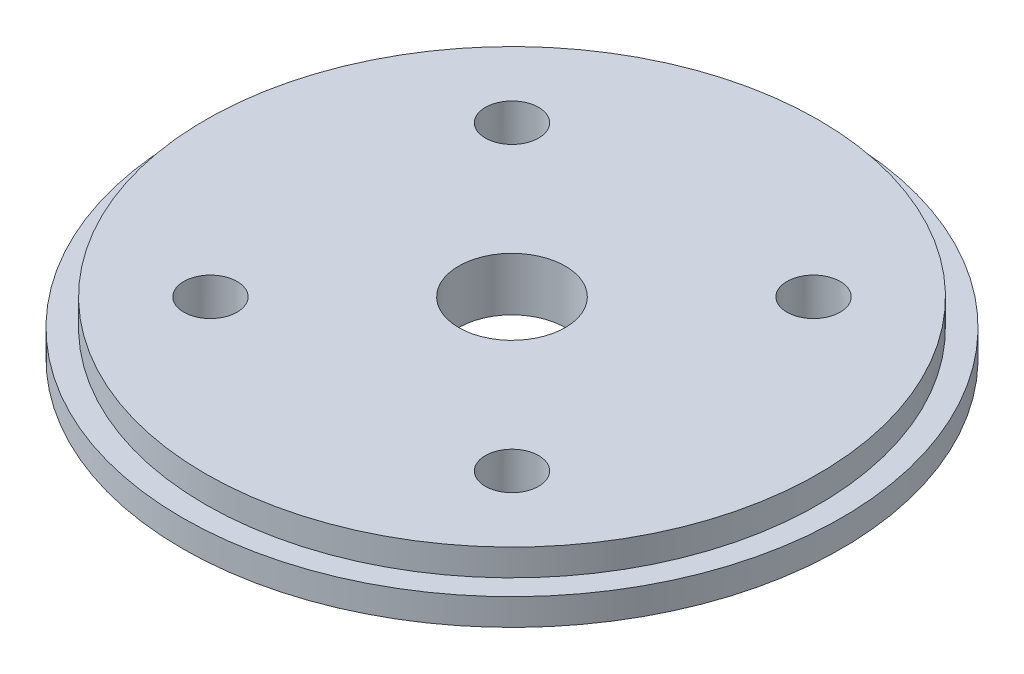
from build123d import *

# Parameters (mm, degrees)
SKETCH2_R                   = 39.2557
BOSS_EXTRUDE1_DEPTH         = 6.35
SKETCH4_R                   = 39.2557
SKETCH4_R_2                 = 36.5125
CUT_EXTRUDE1_DEPTH          = 3.175
F_1_4_0_25_DIAMETER_HOLE1_D = 6.35
F_1_2_0_5_DIAMETER_HOLE1_D  = 12.7
SKETCH9_R                   = 6.0325
CUT_EXTRUDE2_DEPTH          = 1.5875


with BuildPart() as part:
    # Sketch2 → Boss-Extrude1 (new body)
    with BuildSketch(Plane(origin=(0, 0, 0), x_dir=(1, 0, 0), z_dir=(0, 1, 0))):
        Circle(SKETCH2_R)
    extrude(amount=BOSS_EXTRUDE1_DEPTH)

    # Sketch4 → Cut-Extrude1 (cut)
    with BuildSketch(Plane(origin=(0, 6.35, 0), x_dir=(1, 0, 0), z_dir=(0, 1, 0))):
        Circle(SKETCH4_R)
        Circle(SKETCH4_R_2, mode=Mode.SUBTRACT)
    extrude(amount=-CUT_EXTRUDE1_DEPTH, mode=Mode.SUBTRACT)

    # 1/4 (0.25) Diameter Hole1 (through all)
    with Locations(Plane(origin=(0, 6.35, 0), x_dir=(1, 0, 0), z_dir=(0, 1, 0))):
        with Locations((-17.960512242, 17.960512242), (-17.960512242, -17.960512242), (17.960512242, 17.960512242), (17.960512242, -17.960512242)):
            Hole(F_1_4_0_25_DIAMETER_HOLE1_D / 2)

    # 1/2 (0.5) Diameter Hole1 (through all)
    with Locations(Plane(origin=(0, 6.35, 0), x_dir=(1, 0, 0), z_dir=(0, 1, 0))):
        with Locations((0, 0)):
            Hole(F_1_2_0_5_DIAMETER_HOLE1_D / 2)

    # Sketch9 → Cut-Extrude2 (cut)
    with BuildSketch(Plane.XZ):
        with Locations((-17.960512242, 17.960512242)):
            Circle(SKETCH9_R)
        with Locations((17.960512242, 17.960512242)):
            Circle(SKETCH9_R)
        with Locations((17.960512242, -17.960512242)):
            Circle(SKETCH9_R)
        with Locations((-17.960512242, -17.960512242)):
            Circle(SKETCH9_R)
    extrude(amount=-CUT_EXTRUDE2_DEPTH, mode=Mode.SUBTRACT)


solid = part.part
